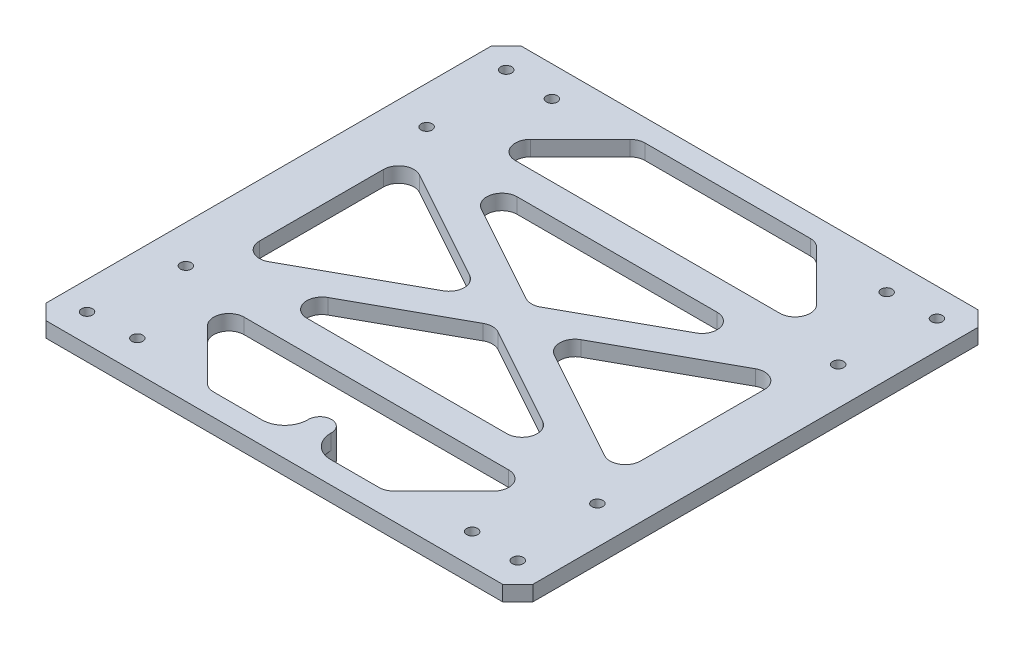
from build123d import *

# Parameters (mm, degrees)
BOSS_EXTRUDE1_DEPTH     = 6.35
SKETCH3_R               = 2.286
CUT_EXTRUDE2_DEPTH      = 7.35
SKETCH4_R               = 2.286
CUT_EXTRUDE3_DEPTH      = 7.35
SKETCH5_W               = 184.404
SKETCH5_H               = 113.157
SKETCH5_R               = 2.286
BOSS_EXTRUDE2_DEPTH     = 6.35
FILLET1_R               = 6.35
BOSS_EXTRUDE3_DEPTH     = 6.35
SKETCH8_R               = 4.826
SKETCH8_R_2             = 2.286
BOSS_EXTRUDE4_DEPTH     = 6.35
SKETCH9_R               = 3.8354
CUT_EXTRUDE4_DEPTH      = 3.81
SKETCH11_R              = 2.286
CUT_EXTRUDE6_DEPTH      = 7.35
CUT_EXTRUDE6_DEPTH_BACK = 7.35
SKETCH12_R              = 4.7625
CUT_EXTRUDE7_DEPTH      = 6.35
SKETCH16_W              = 12.7
SKETCH16_H              = 12.7
BOSS_EXTRUDE6_DEPTH     = 5.08


with BuildPart() as part:
    # Sketch1 → Boss-Extrude1 (new body)
    with BuildSketch(Plane(origin=(0, 0, 0), x_dir=(1, 0, 0), z_dir=(0, 1, 0))):
        Polygon((0, 192.024), (6.35, 198.374), (196.85, 198.374), (203.2, 192.024), (203.2, 6.35), (196.85, 0), (6.35, 0), (0, 6.35), align=None)
    extrude(amount=BOSS_EXTRUDE1_DEPTH)

    # Sketch3 → Cut-Extrude2 (cut, through all)
    with BuildSketch(Plane(origin=(0, 6.35, 0), x_dir=(1, 0, 0), z_dir=(0, 1, 0))):
        with Locations((11.73734, 11.73734)):
            Circle(SKETCH3_R)
        with Locations((191.46266, 11.73734)):
            Circle(SKETCH3_R)
        with Locations((191.46266, 186.63666)):
            Circle(SKETCH3_R)
        with Locations((11.73734, 186.63666)):
            Circle(SKETCH3_R)
    extrude(amount=-CUT_EXTRUDE2_DEPTH, mode=Mode.SUBTRACT)

    # Sketch4 → Cut-Extrude3 (cut, through all)
    with BuildSketch(Plane(origin=(0, 6.35, 0), x_dir=(1, 0, 0), z_dir=(0, 1, 0))):
        with Locations((15.748, 149.4155)):
            Circle(SKETCH4_R)
        with Locations((187.452, 149.4155)):
            Circle(SKETCH4_R)
        with Locations((187.452, 48.9585)):
            Circle(SKETCH4_R)
        with Locations((15.748, 48.9585)):
            Circle(SKETCH4_R)
        Polygon((12.573, 137.260243879), (64.490719308, 189.177963187), (138.709280692, 189.177963187), (190.627, 137.260243879), (190.627, 61.113756121), (138.709280692, 9.196036813), (64.490719308, 9.196036813), (12.573, 61.113756121), align=None)
    extrude(amount=-CUT_EXTRUDE3_DEPTH, mode=Mode.SUBTRACT)

    # Sketch5 → Boss-Extrude2 (add)
    with BuildSketch(Plane(origin=(0, 6.35, 0), x_dir=(1, 0, 0), z_dir=(0, 1, 0))):
        with Locations((101.6, 99.187)):
            Rectangle(SKETCH5_W, SKETCH5_H)
        with Locations((187.452, 48.9585)):
            Circle(SKETCH5_R, mode=Mode.SUBTRACT)
        with Locations((187.452, 149.4155)):
            Circle(SKETCH5_R, mode=Mode.SUBTRACT)
        with Locations((15.748, 149.4155)):
            Circle(SKETCH5_R, mode=Mode.SUBTRACT)
        with Locations((15.748, 48.9585)):
            Circle(SKETCH5_R, mode=Mode.SUBTRACT)
        with BuildLine():
            Line((143.313899503, 143.0655), (59.886100497, 143.0655))
            ThreePointArc((59.886100497, 143.0655), (53.736909414, 138.299781862), (56.817737694, 131.156035124))
            Line((56.817737694, 131.156035124), (98.531637197, 108.133427651))
            ThreePointArc((98.531637197, 108.133427651), (101.6, 107.342892527), (104.668362803, 108.133427651))
            Line((104.668362803, 108.133427651), (146.382262306, 131.156035124))
            ThreePointArc((146.382262306, 131.156035124), (149.463090586, 138.299781862), (143.313899503, 143.0655))
        make_face(mode=Mode.SUBTRACT)
        with BuildLine():
            Line((22.098, 125.054934949), (22.098, 73.319065051))
            ThreePointArc((22.098, 73.319065051), (25.220121734, 67.850673889), (31.516362803, 67.759600175))
            Line((31.516362803, 67.759600175), (78.385616864, 93.627535124))
            ThreePointArc((78.385616864, 93.627535124), (81.667254061, 99.187), (78.385616864, 104.746464876))
            Line((78.385616864, 104.746464876), (31.516362803, 130.614399825))
            ThreePointArc((31.516362803, 130.614399825), (25.220121734, 130.523326111), (22.098, 125.054934949))
        make_face(mode=Mode.SUBTRACT)
        with BuildLine():
            Line((59.886100497, 55.3085), (143.313899503, 55.3085))
            ThreePointArc((143.313899503, 55.3085), (149.463090586, 60.074218138), (146.382262306, 67.217964876))
            Line((146.382262306, 67.217964876), (104.668362803, 90.240572349))
            ThreePointArc((104.668362803, 90.240572349), (101.6, 91.031107473), (98.531637197, 90.240572349))
            Line((98.531637197, 90.240572349), (56.817737694, 67.217964876))
            ThreePointArc((56.817737694, 67.217964876), (53.736909414, 60.074218138), (59.886100497, 55.3085))
        make_face(mode=Mode.SUBTRACT)
        with BuildLine():
            Line((181.102, 73.319065051), (181.102, 125.054934949))
            ThreePointArc((181.102, 125.054934949), (177.979878266, 130.523326111), (171.683637197, 130.614399825))
            Line((171.683637197, 130.614399825), (124.814383136, 104.746464876))
            ThreePointArc((124.814383136, 104.746464876), (121.532745939, 99.187), (124.814383136, 93.627535124))
            Line((124.814383136, 93.627535124), (171.683637197, 67.759600175))
            ThreePointArc((171.683637197, 67.759600175), (177.979878266, 67.850673889), (181.102, 73.319065051))
        make_face(mode=Mode.SUBTRACT)
    extrude(amount=-BOSS_EXTRUDE2_DEPTH)

    # Fillet1
    fillet1_edges = [part.edges().sort_by_distance(p)[0] for p in [
        (64.490719308, 3.175, -189.177963187),
        (138.709280692, 3.175, -189.177963187),
        (138.709280692, 3.175, -9.196036813),
        (64.490719308, 3.175, -9.196036813),
        (31.078256121, 3.175, -42.6085),
        (172.121743879, 3.175, -155.7655),
        (31.078256121, 3.175, -155.7655),
        (172.121743879, 3.175, -42.6085),
    ]]
    fillet(fillet1_edges, radius=FILLET1_R)

    # Sketch6 → Boss-Extrude3 (add)
    with BuildSketch(Plane(origin=(0, 6.35, 0), x_dir=(1, 0, 0), z_dir=(0, 1, 0))):
        with BuildLine():
            Line((87.252770852, 9.196036813), (115.947229148, 9.196036813))
            ThreePointArc((115.947229148, 9.196036813), (109.135280152, 12.063486522), (106.424731926, 18.939375212))
            ThreePointArc((106.424731926, 18.939375212), (101.6, 23.876), (96.775268074, 18.939375212))
            ThreePointArc((96.775268074, 18.939375212), (94.064719848, 12.063486522), (87.252770852, 9.196036813))
        make_face()
    extrude(amount=-BOSS_EXTRUDE3_DEPTH)

    # Sketch8 → Boss-Extrude4 (add)
    with BuildSketch(Plane(origin=(0, 0, 0), x_dir=(1, 0, 0), z_dir=(0, 1, 0))):
        with Locations((101.6, 19.05)):
            Circle(SKETCH8_R)
        with Locations((101.6, 19.05)):
            Circle(SKETCH8_R_2, mode=Mode.SUBTRACT)
    extrude(amount=-BOSS_EXTRUDE4_DEPTH)

    # Sketch9 → Cut-Extrude4 (cut)
    with BuildSketch(Plane(origin=(0, 0, 0), x_dir=(1, 0, 0), z_dir=(0, 1, 0))):
        with Locations((81.233070117, 111.102859125)):
            Circle(SKETCH9_R)
        with Locations((121.966929883, 111.102859125)):
            Circle(SKETCH9_R)
        with Locations((121.966929883, 87.271140875)):
            Circle(SKETCH9_R)
        with Locations((81.233070117, 87.271140875)):
            Circle(SKETCH9_R)
    extrude(amount=CUT_EXTRUDE4_DEPTH, mode=Mode.SUBTRACT)

    # Sketch11 → Cut-Extrude6 (cut, two sides)
    with BuildSketch(Plane.XZ) as cut_extrude6_sk:
        with Locations((31.75, -12.7)):
            Circle(SKETCH11_R)
        with Locations((171.45, -12.7)):
            Circle(SKETCH11_R)
        with Locations((171.45, -185.674)):
            Circle(SKETCH11_R)
        with Locations((31.75, -185.674)):
            Circle(SKETCH11_R)
    extrude(amount=CUT_EXTRUDE6_DEPTH, mode=Mode.SUBTRACT)
    extrude(cut_extrude6_sk.sketch, amount=-CUT_EXTRUDE6_DEPTH_BACK, mode=Mode.SUBTRACT)

    # Sketch12 → Cut-Extrude7 (cut)
    with BuildSketch(Plane(origin=(0, 6.35, 0), x_dir=(1, 0, 0), z_dir=(0, 1, 0))):
        with Locations((100.413067708, 99.782171875)):
            Circle(SKETCH12_R)
    extrude(amount=-CUT_EXTRUDE7_DEPTH, mode=Mode.SUBTRACT)

    # Sketch16 → Boss-Extrude6 (add)
    with BuildSketch(Plane(origin=(0, 6.35, 0), x_dir=(1, 0, 0), z_dir=(0, 1, 0))):
        with Locations((100.413067708, 99.782171875)):
            Rectangle(SKETCH16_W, SKETCH16_H)
    extrude(amount=-BOSS_EXTRUDE6_DEPTH)


solid = part.part
